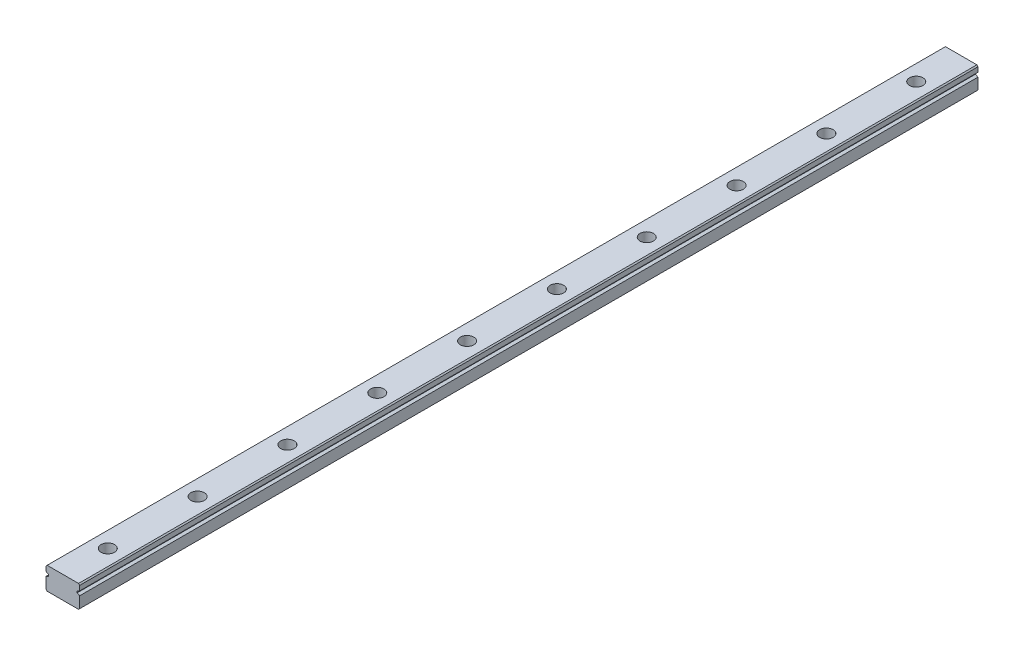
from build123d import *

# Parameters (mm, degrees)
EXTRUDE_1_DEPTH           = 400
HOLE_WIZARD_2_D           = 3.2
HOLE_WIZARD_2_CBORE_D     = 6
HOLE_WIZARD_2_CBORE_DEPTH = 4.5


with BuildPart() as part:
    # 草图1 → 凸台-拉伸1 (new body)
    with BuildSketch(Plane.XY):
        Polygon((-3.269035533, 4.949238579), (10.730964467, 4.949238579), (11.230964467, 4.449238579), (11.230964467, 2.317517259), (10.086764657, 1.783377919), (10.086764657, 0.983377919), (11.230964467, 0.449238579), (11.230964467, -4.550761421), (10.730964467, -5.050761421), (-3.269035533, -5.050761421), (-3.769035533, -4.550761421), (-3.769035533, 0.449238579), (-2.624835723, 0.983377919), (-2.624835723, 1.783377919), (-3.769035533, 2.317517259), (-3.769035533, 4.449238579), align=None)
    extrude(amount=-EXTRUDE_1_DEPTH)

    # 孔2 (through all)
    with Locations(Plane(origin=(3.730964467, 4.949238579, -380), x_dir=(0, 0, 1), z_dir=(0, 1, 0))):
        with Locations((0, 0), (40, 0), (80, 0), (120, 0), (160, 0), (200, 0), (240, 0), (280, 0), (320, 0), (360, 0)):
            CounterBoreHole(HOLE_WIZARD_2_D / 2, HOLE_WIZARD_2_CBORE_D / 2, HOLE_WIZARD_2_CBORE_DEPTH)


solid = part.part
